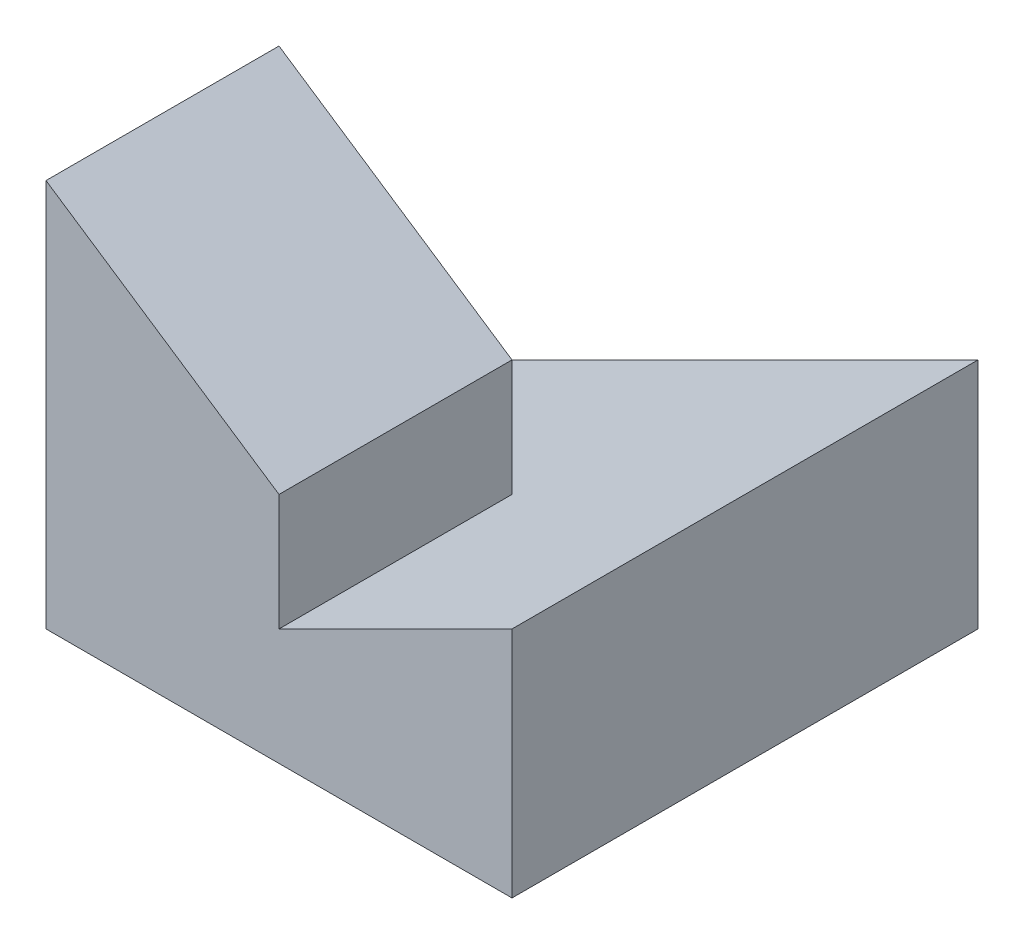
from build123d import *

# Parameters (mm, degrees)
SKETCH1_W           = 6
SKETCH1_H           = 6
BOSS_EXTRUDE1_DEPTH = 5
CUT_EXTRUDE5_DEPTH  = 3
CUT_EXTRUDE6_DEPTH  = 3


with BuildPart() as part:
    # Sketch1 → Boss-Extrude1 (new body)
    with BuildSketch(Plane(origin=(0, 0, 0), x_dir=(1, 0, 0), z_dir=(0, 1, 0))):
        Rectangle(SKETCH1_W, SKETCH1_H)
    extrude(amount=BOSS_EXTRUDE1_DEPTH)

    # Sketch8 → Cut-Extrude5 (cut)
    with BuildSketch(Plane.XY.offset(3)):
        Polygon((3, 3), (0, 1.5), (0, 3), (-3, 5), (3, 5), align=None)
    extrude(amount=-CUT_EXTRUDE5_DEPTH, mode=Mode.SUBTRACT)

    # Sketch9 → Cut-Extrude6 (cut)
    with BuildSketch(Plane(origin=(0, 0, -3), x_dir=(-1, 0, 0), z_dir=(0, 0, -1))):
        Polygon((-3, 5), (-3, 3), (0, 1.5), (3, 0), (3, 5), align=None)
    extrude(amount=-CUT_EXTRUDE6_DEPTH, mode=Mode.SUBTRACT)


solid = part.part
